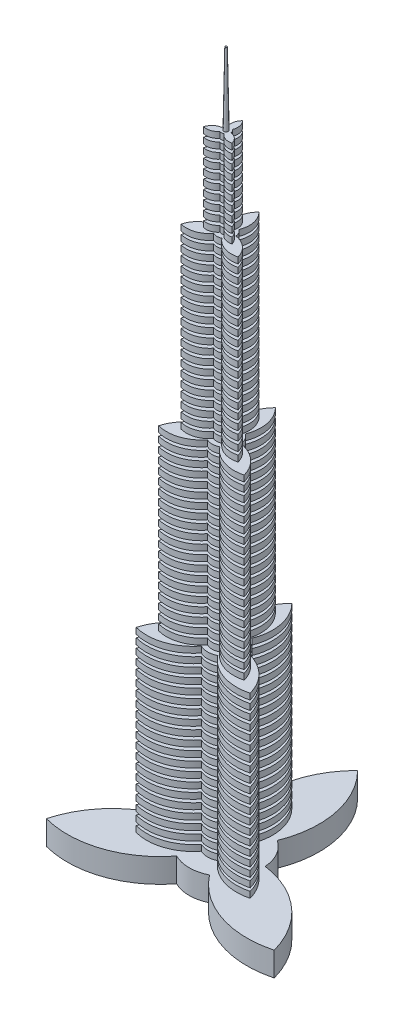
from build123d import *

# Parameters (mm, degrees)
BOSS_EXTRUDE1_DEPTH = 10
LPATTERN1_COUNT     = 20
LPATTERN1_PITCH     = 15
BOSS_EXTRUDE2_DEPTH = 10
LPATTERN2_COUNT     = 20
LPATTERN2_PITCH     = 15
BOSS_EXTRUDE3_DEPTH = 10
LPATTERN3_COUNT     = 20
LPATTERN3_PITCH     = 15
BOSS_EXTRUDE4_DEPTH = 10
LPATTERN4_COUNT     = 10
LPATTERN4_PITCH     = 15
SKETCH5_R           = 3.630455641
BOSS_EXTRUDE5_DEPTH = 120
BOSS_EXTRUDE5_TAPER = 1
BOSS_EXTRUDE6_DEPTH = 40


with BuildPart() as part:
    # Sketch1 → Boss-Extrude1 (new body)
    with BuildSketch(Plane(origin=(0, 0, 0), x_dir=(1, 0, 0), z_dir=(0, 1, 0))):
        with BuildLine():
            ThreePointArc((-13.632044223, -27.421382707), (0, -30.622946613), (13.632044223, -27.421382707))
            ThreePointArc((13.632044223, -27.421382707), (50.015192012, -53.229636208), (94.600755502, -54.617771655))
            ThreePointArc((94.600755502, -54.617771655), (71.105813196, -16.699608753), (30.563636142, 1.904994751))
            ThreePointArc((30.563636142, 1.904994751), (26.520249705, 15.311473306), (16.931591919, 25.516387956))
            ThreePointArc((16.931591919, 25.516387956), (21.090621184, 69.929244961), (0, 109.23554331))
            ThreePointArc((0, 109.23554331), (-21.090621184, 69.929244961), (-16.931591919, 25.516387956))
            ThreePointArc((-16.931591919, 25.516387956), (-26.520249705, 15.311473306), (-30.563636142, 1.904994751))
            ThreePointArc((-30.563636142, 1.904994751), (-71.105813196, -16.699608753), (-94.600755502, -54.617771655))
            ThreePointArc((-94.600755502, -54.617771655), (-50.015192012, -53.229636208), (-13.632044223, -27.421382707))
        make_face()
    extrude(amount=BOSS_EXTRUDE1_DEPTH)


with BuildPart() as lpattern1_1:
    # LPattern1: pattern copy
    add(part.part.moved(Location(Vector(0, 1, 0) * (1 * LPATTERN1_PITCH))))


with BuildPart() as lpattern1_2:
    # LPattern1: pattern copy
    add(part.part.moved(Location(Vector(0, 1, 0) * (2 * LPATTERN1_PITCH))))


with BuildPart() as lpattern1_3:
    # LPattern1: pattern copy
    add(part.part.moved(Location(Vector(0, 1, 0) * (3 * LPATTERN1_PITCH))))


with BuildPart() as lpattern1_4:
    # LPattern1: pattern copy
    add(part.part.moved(Location(Vector(0, 1, 0) * (4 * LPATTERN1_PITCH))))


with BuildPart() as lpattern1_5:
    # LPattern1: pattern copy
    add(part.part.moved(Location(Vector(0, 1, 0) * (5 * LPATTERN1_PITCH))))


with BuildPart() as lpattern1_6:
    # LPattern1: pattern copy
    add(part.part.moved(Location(Vector(0, 1, 0) * (6 * LPATTERN1_PITCH))))


with BuildPart() as lpattern1_7:
    # LPattern1: pattern copy
    add(part.part.moved(Location(Vector(0, 1, 0) * (7 * LPATTERN1_PITCH))))


with BuildPart() as lpattern1_8:
    # LPattern1: pattern copy
    add(part.part.moved(Location(Vector(0, 1, 0) * (8 * LPATTERN1_PITCH))))


with BuildPart() as lpattern1_9:
    # LPattern1: pattern copy
    add(part.part.moved(Location(Vector(0, 1, 0) * (9 * LPATTERN1_PITCH))))


with BuildPart() as lpattern1_10:
    # LPattern1: pattern copy
    add(part.part.moved(Location(Vector(0, 1, 0) * (10 * LPATTERN1_PITCH))))


with BuildPart() as lpattern1_11:
    # LPattern1: pattern copy
    add(part.part.moved(Location(Vector(0, 1, 0) * (11 * LPATTERN1_PITCH))))


with BuildPart() as lpattern1_12:
    # LPattern1: pattern copy
    add(part.part.moved(Location(Vector(0, 1, 0) * (12 * LPATTERN1_PITCH))))


with BuildPart() as lpattern1_13:
    # LPattern1: pattern copy
    add(part.part.moved(Location(Vector(0, 1, 0) * (13 * LPATTERN1_PITCH))))


with BuildPart() as lpattern1_14:
    # LPattern1: pattern copy
    add(part.part.moved(Location(Vector(0, 1, 0) * (14 * LPATTERN1_PITCH))))


with BuildPart() as lpattern1_15:
    # LPattern1: pattern copy
    add(part.part.moved(Location(Vector(0, 1, 0) * (15 * LPATTERN1_PITCH))))


with BuildPart() as lpattern1_16:
    # LPattern1: pattern copy
    add(part.part.moved(Location(Vector(0, 1, 0) * (16 * LPATTERN1_PITCH))))


with BuildPart() as lpattern1_17:
    # LPattern1: pattern copy
    add(part.part.moved(Location(Vector(0, 1, 0) * (17 * LPATTERN1_PITCH))))


with BuildPart() as lpattern1_18:
    # LPattern1: pattern copy
    add(part.part.moved(Location(Vector(0, 1, 0) * (18 * LPATTERN1_PITCH))))


with BuildPart() as lpattern1_19:
    # LPattern1: pattern copy
    add(part.part.moved(Location(Vector(0, 1, 0) * (19 * LPATTERN1_PITCH))))

    # Sketch2 → Boss-Extrude2 (add)
    with BuildSketch(Plane(origin=(0, 295, 0), x_dir=(1, 0, 0), z_dir=(0, 1, 0))):
        with BuildLine():
            ThreePointArc((10.224033167, -20.56603703), (37.511394009, -39.922227156), (70.950566627, -40.963328741))
            ThreePointArc((70.950566627, -40.963328741), (53.329359897, -12.524706565), (22.922727107, 1.428746063))
            ThreePointArc((22.922727107, 1.428746063), (19.890187279, 11.48360498), (12.69869394, 19.137290967))
            ThreePointArc((12.69869394, 19.137290967), (15.817965888, 52.446933721), (0, 81.926657482))
            ThreePointArc((0, 81.926657482), (-15.817965888, 52.446933721), (-12.69869394, 19.137290967))
            ThreePointArc((-12.69869394, 19.137290967), (-19.890187279, 11.48360498), (-22.922727107, 1.428746063))
            ThreePointArc((-22.922727107, 1.428746063), (-53.329359897, -12.524706565), (-70.950566627, -40.963328741))
            ThreePointArc((-70.950566627, -40.963328741), (-37.511394009, -39.922227156), (-10.224033167, -20.56603703))
            ThreePointArc((-10.224033167, -20.56603703), (0, -22.967209959), (10.224033167, -20.56603703))
        make_face()
    boss_extrude2 = extrude(amount=BOSS_EXTRUDE2_DEPTH)


with BuildPart() as lpattern2_1:
    # LPattern2: Boss-Extrude2 ×20
    with Locations(*[(0, i * LPATTERN2_PITCH, 0) for i in range(1, LPATTERN2_COUNT)]):
        add(boss_extrude2)

    # Sketch3 → Boss-Extrude3 (add)
    with BuildSketch(Plane(origin=(0, 590, 0), x_dir=(1, 0, 0), z_dir=(0, 1, 0))):
        with BuildLine():
            ThreePointArc((6.816022111, -13.710691353), (25.007596006, -26.614818104), (47.300377751, -27.308885827))
            ThreePointArc((47.300377751, -27.308885827), (35.552906598, -8.349804377), (15.281818071, 0.952497375))
            ThreePointArc((15.281818071, 0.952497375), (13.260124853, 7.655736653), (8.46579596, 12.758193978))
            ThreePointArc((8.46579596, 12.758193978), (10.545310592, 34.964622481), (0, 54.617771655))
            ThreePointArc((0, 54.617771655), (-10.545310592, 34.964622481), (-8.46579596, 12.758193978))
            ThreePointArc((-8.46579596, 12.758193978), (-13.260124853, 7.655736653), (-15.281818071, 0.952497375))
            ThreePointArc((-15.281818071, 0.952497375), (-35.552906598, -8.349804377), (-47.300377751, -27.308885827))
            ThreePointArc((-47.300377751, -27.308885827), (-25.007596006, -26.614818104), (-6.816022111, -13.710691353))
            ThreePointArc((-6.816022111, -13.710691353), (0, -15.311473306), (6.816022111, -13.710691353))
        make_face()
    boss_extrude3 = extrude(amount=BOSS_EXTRUDE3_DEPTH)


with BuildPart() as lpattern3_1:
    # LPattern3: Boss-Extrude3 ×20
    with Locations(*[(0, i * LPATTERN3_PITCH, 0) for i in range(1, LPATTERN3_COUNT)]):
        add(boss_extrude3)

    # Sketch4 → Boss-Extrude4 (add)
    with BuildSketch(Plane(origin=(0, 885, 0), x_dir=(1, 0, 0), z_dir=(0, 1, 0))):
        with BuildLine():
            ThreePointArc((3.408011056, -6.855345677), (12.503798003, -13.307409052), (23.650188876, -13.654442914))
            ThreePointArc((23.650188876, -13.654442914), (17.776453299, -4.174902188), (7.640909036, 0.476248688))
            ThreePointArc((7.640909036, 0.476248688), (6.630062426, 3.827868327), (4.23289798, 6.379096989))
            ThreePointArc((4.23289798, 6.379096989), (5.272655296, 17.48231124), (0, 27.308885827))
            ThreePointArc((0, 27.308885827), (-5.272655296, 17.48231124), (-4.23289798, 6.379096989))
            ThreePointArc((-4.23289798, 6.379096989), (-6.630062426, 3.827868327), (-7.640909036, 0.476248688))
            ThreePointArc((-7.640909036, 0.476248688), (-17.776453299, -4.174902188), (-23.650188876, -13.654442914))
            ThreePointArc((-23.650188876, -13.654442914), (-12.503798003, -13.307409052), (-3.408011056, -6.855345677))
            ThreePointArc((-3.408011056, -6.855345677), (0, -7.655736653), (3.408011056, -6.855345677))
        make_face()
    boss_extrude4 = extrude(amount=BOSS_EXTRUDE4_DEPTH)


with BuildPart() as lpattern4_1:
    # LPattern4: Boss-Extrude4 ×10
    with Locations(*[(0, i * LPATTERN4_PITCH, 0) for i in range(1, LPATTERN4_COUNT)]):
        add(boss_extrude4)

    # Sketch5 → Boss-Extrude5 (add)
    with BuildSketch(Plane(origin=(0, 1030, 0), x_dir=(1, 0, 0), z_dir=(0, 1, 0))):
        Circle(SKETCH5_R)
    extrude(amount=BOSS_EXTRUDE5_DEPTH, taper=BOSS_EXTRUDE5_TAPER)


with BuildPart() as part_1:
    add(part.part)

    # Sketch6 → Boss-Extrude6 (add)
    with BuildSketch(Plane.XZ):
        with BuildLine():
            ThreePointArc((189.201511005, 109.23554331), (100.030384023, 106.459272415), (27.264088446, 54.842765413))
            ThreePointArc((27.264088446, 54.842765413), (0, 61.245893225), (-27.264088446, 54.842765413))
            ThreePointArc((-27.264088446, 54.842765413), (-100.030384023, 106.459272415), (-189.201511005, 109.23554331))
            ThreePointArc((-189.201511005, 109.23554331), (-142.211626392, 33.399217507), (-61.127272285, -3.809989502))
            ThreePointArc((-61.127272285, -3.809989502), (-53.040499411, -30.622946613), (-33.863183839, -51.032775912))
            ThreePointArc((-33.863183839, -51.032775912), (-42.181242368, -139.858489922), (0, -218.471086619))
            ThreePointArc((0, -218.471086619), (42.181242368, -139.858489922), (33.863183839, -51.032775912))
            ThreePointArc((33.863183839, -51.032775912), (53.040499411, -30.622946613), (61.127272285, -3.809989502))
            ThreePointArc((61.127272285, -3.809989502), (142.211626392, 33.399217507), (189.201511005, 109.23554331))
        make_face()
    extrude(amount=BOSS_EXTRUDE6_DEPTH)


solid = Compound([lpattern1_1.part, lpattern1_2.part, lpattern1_3.part, lpattern1_4.part, lpattern1_5.part, lpattern1_6.part, lpattern1_7.part, lpattern1_8.part, lpattern1_9.part, lpattern1_10.part, lpattern1_11.part, lpattern1_12.part, lpattern1_13.part, lpattern1_14.part, lpattern1_15.part, lpattern1_16.part, lpattern1_17.part, lpattern1_18.part, lpattern1_19.part, lpattern2_1.part, lpattern3_1.part, lpattern4_1.part, part_1.part])
